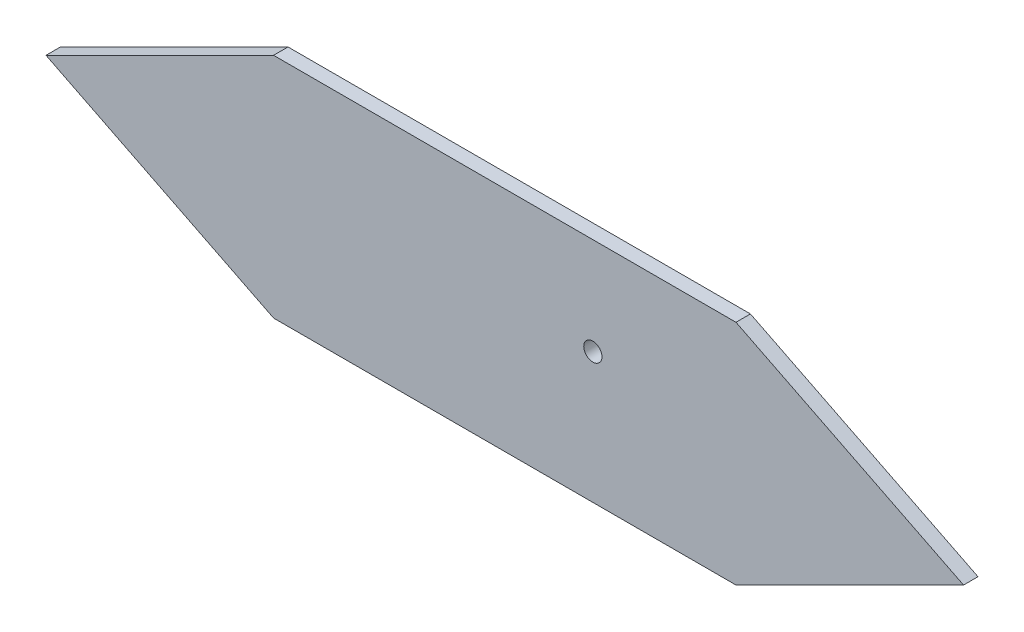
from build123d import *

# Parameters (mm, degrees)
BOSS_EXTRUDE1_DEPTH = 6.35
BOSS_EXTRUDE3_DEPTH = 25
SKETCH3_R           = 4
CUT_EXTRUDE1_DEPTH  = 25


with BuildPart() as part:
    # Sketch1 → Boss-Extrude1 (new body)
    with BuildSketch(Plane.XY):
        Polygon((0, 0), (203.2, 0), (303.2, 50), (203.2, 100), (0, 100), (-100, 50), align=None)
    extrude(amount=BOSS_EXTRUDE1_DEPTH)

    # Sketch2 → Boss-Extrude3 (add)
    with BuildSketch(Plane(origin=(0, 0, 0), x_dir=(-1, 0, 0), z_dir=(0, 0, -1))):
        Polygon((-177.8, 12.7), (-203.2, 12.7), (-203.2, 19.05), (-177.8, 19.05), (-177.8, 25.05), (-209.2, 25.05), (-209.2, 6.7), (-177.8, 6.7), align=None)
        Polygon((6, 6.7), (6, 25.05), (-25.4, 25.05), (-25.4, 19.05), (0, 19.05), (0, 12.7), (-25.4, 12.7), (-25.4, 6.7), align=None)
    extrude(amount=BOSS_EXTRUDE3_DEPTH)

    # Sketch3 → Cut-Extrude1 (cut)
    with BuildSketch(Plane(origin=(0, 0, 0), x_dir=(-1, 0, 0), z_dir=(0, 0, -1))):
        with Locations((-140.3, 57.4)):
            Circle(SKETCH3_R)
    extrude(amount=-CUT_EXTRUDE1_DEPTH, mode=Mode.SUBTRACT)


solid = part.part
